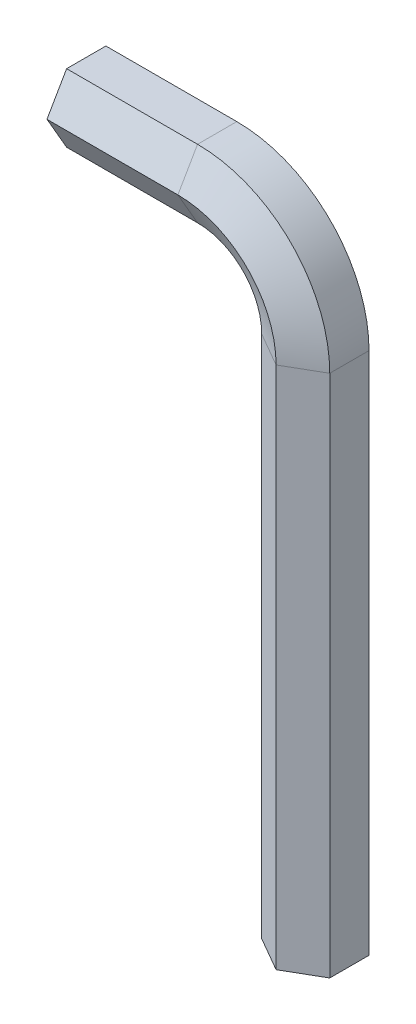
from build123d import *


with BuildPart() as part:
    # Sweep1: sweep along a path in Sketch1
    with BuildLine(Plane.XY) as sweep1_path:
        Line((0, 0), (0, 80))
        ThreePointArc((0, 80), (-4.393398282, 90.606601718), (-15, 95))
        Line((-15, 95), (-35, 95))
    # Sketch2 → Sweep1 (sweep)
    with BuildSketch(Plane(origin=(-35, 95, 0), x_dir=(0, 0, 1), z_dir=(-1, 0, 0))):
        Polygon((6, 0), (3, 5.196152423), (-3, 5.196152423), (-6, 0), (-3, -5.196152423), (3, -5.196152423), align=None)
    sweep(path=sweep1_path.line)


solid = part.part
